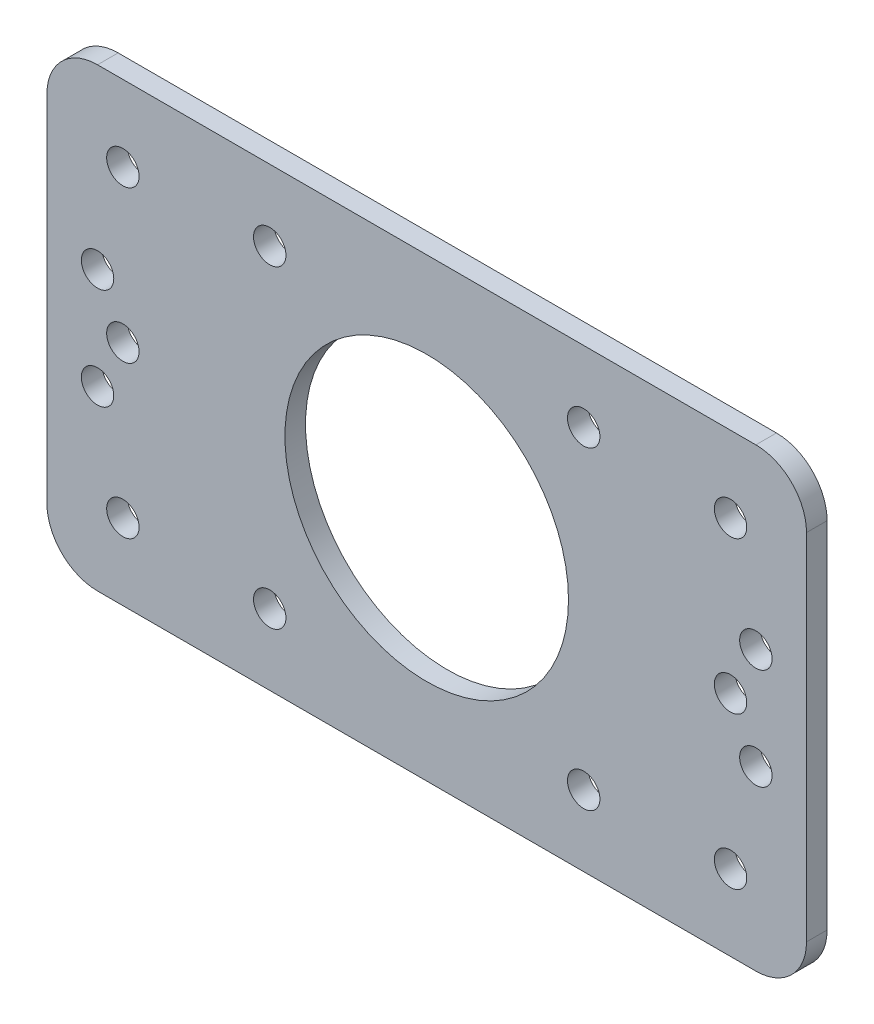
from build123d import *

# Parameters (mm, degrees)
SKETCH1_W           = 75
SKETCH1_H           = 45
SKETCH1_R           = 14
SKETCH1_R_2         = 1.6
BOSS_EXTRUDE1_DEPTH = 2.032
FILLET2_R           = 5
SKETCH2_R           = 1.6
CUT_EXTRUDE1_DEPTH  = 3.032
SKETCH3_R           = 1.6
CUT_EXTRUDE2_DEPTH  = 3.032


with BuildPart() as part:
    # Sketch1 → Boss-Extrude1 (new body)
    with BuildSketch(Plane.XY):
        Rectangle(SKETCH1_W, SKETCH1_H)
        Circle(SKETCH1_R, mode=Mode.SUBTRACT)
        with Locations((-15.5, 15.5)):
            Circle(SKETCH1_R_2, mode=Mode.SUBTRACT)
        with Locations((15.5, 15.5)):
            Circle(SKETCH1_R_2, mode=Mode.SUBTRACT)
        with Locations((15.5, -15.5)):
            Circle(SKETCH1_R_2, mode=Mode.SUBTRACT)
        with Locations((-15.5, -15.5)):
            Circle(SKETCH1_R_2, mode=Mode.SUBTRACT)
    extrude(amount=BOSS_EXTRUDE1_DEPTH)

    # Fillet2
    fillet2_edges = [part.edges().sort_by_distance(p)[0] for p in [
        (37.5, -22.5, 1.016),
        (-37.5, -22.5, 1.016),
        (-37.5, 22.5, 1.016),
        (37.5, 22.5, 1.016),
    ]]
    fillet(fillet2_edges, radius=FILLET2_R)

    # Sketch2 → Cut-Extrude1 (cut, through all)
    with BuildSketch(Plane.XY.offset(2.032)):
        with Locations((-30, 0)):
            Circle(SKETCH2_R)
        with Locations((-30, 15)):
            Circle(SKETCH2_R)
        with Locations((-30, -15)):
            Circle(SKETCH2_R)
        with Locations((30, -15)):
            Circle(SKETCH2_R)
        with Locations((30, 15)):
            Circle(SKETCH2_R)
        with Locations((30, 0)):
            Circle(SKETCH2_R)
    extrude(amount=-CUT_EXTRUDE1_DEPTH, mode=Mode.SUBTRACT)

    # Sketch3 → Cut-Extrude2 (cut, through all)
    with BuildSketch(Plane(origin=(0, 0, 0), x_dir=(-1, 0, 0), z_dir=(0, 0, -1))):
        with Locations((-32.5, 5)):
            Circle(SKETCH3_R)
        with Locations((-32.5, -5)):
            Circle(SKETCH3_R)
        with Locations((32.5, -5)):
            Circle(SKETCH3_R)
        with Locations((32.5, 5)):
            Circle(SKETCH3_R)
    extrude(amount=-CUT_EXTRUDE2_DEPTH, mode=Mode.SUBTRACT)


solid = part.part
